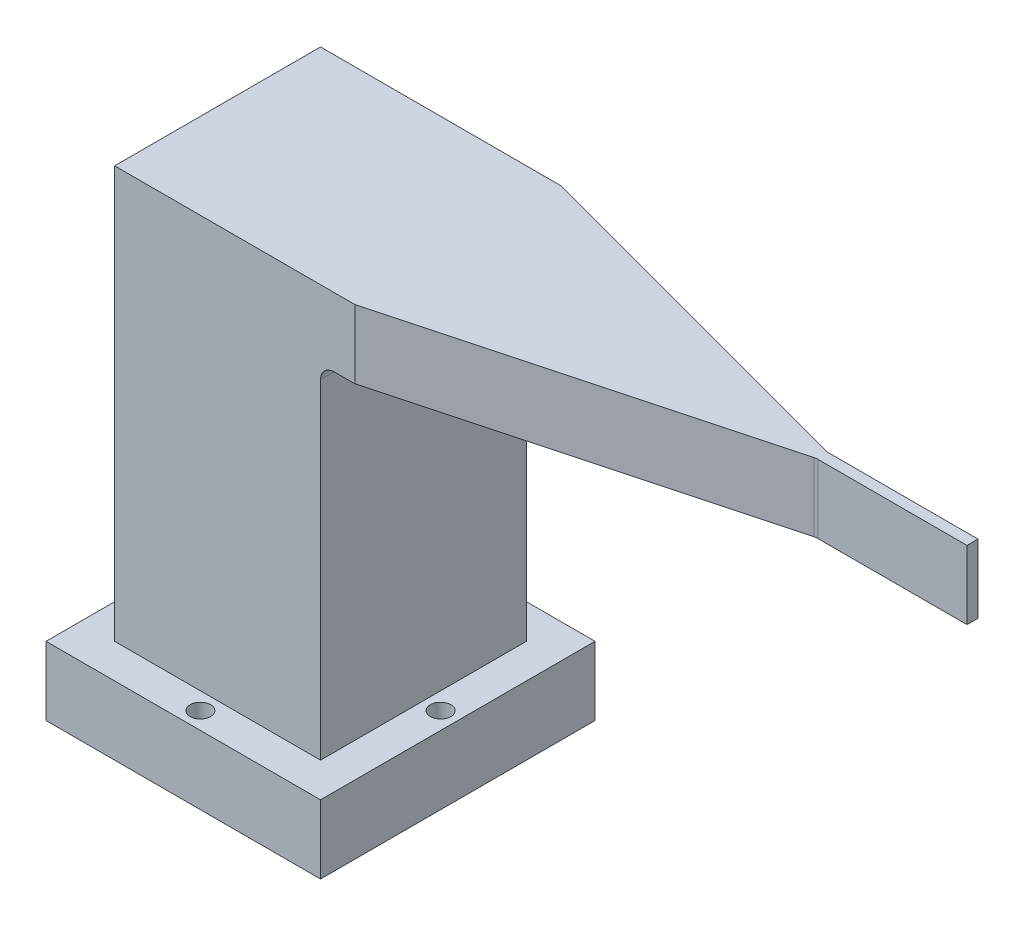
from build123d import *

# Parameters (mm, degrees)
ESQUISSE1_W             = 20
ESQUISSE1_H             = 20
BOSS_EXTRU_1_DEPTH      = 5
ESQUISSE2_W             = 15
ESQUISSE2_H             = 15
BOSS_EXTRU_2_DEPTH      = 35
ESQUISSE3_R             = 0.75
ENL_V_MAT_EXTRU_1_DEPTH = 5
ESQUISSE5_W             = 15
ESQUISSE5_H             = 5
BOSS_EXTRU_3_DEPTH      = 40
ENL_V_MAT_EXTRU_2_DEPTH = 5
CONG_1_R                = 1


with BuildPart() as part:
    # Esquisse1 → Boss.-Extru.1 (new body)
    with BuildSketch(Plane(origin=(0, 0, 0), x_dir=(1, 0, 0), z_dir=(0, 1, 0))):
        Rectangle(ESQUISSE1_W, ESQUISSE1_H)
    extrude(amount=BOSS_EXTRU_1_DEPTH)

    # Esquisse2 → Boss.-Extru.2 (add)
    with BuildSketch(Plane(origin=(0, 0, 0), x_dir=(-1, 0, 0), z_dir=(0, -1, 0))):
        Rectangle(ESQUISSE2_W, ESQUISSE2_H)
    extrude(amount=-BOSS_EXTRU_2_DEPTH)

    # Esquisse3 → Enlèv. mat.-Extru.1 (cut)
    with BuildSketch(Plane(origin=(0, 5, 0), x_dir=(1, 0, 0), z_dir=(0, 1, 0))):
        with Locations((-8.75, 0)):
            Circle(ESQUISSE3_R)
        with Locations((0, 8.75)):
            Circle(ESQUISSE3_R)
        with Locations((8.75, 0)):
            Circle(ESQUISSE3_R)
        with Locations((0, -8.75)):
            Circle(ESQUISSE3_R)
    extrude(amount=-ENL_V_MAT_EXTRU_1_DEPTH, mode=Mode.SUBTRACT)

    # Esquisse5 → Boss.-Extru.3 (add)
    with BuildSketch(Plane(origin=(7.5, 0, 0), x_dir=(0, 0, -1), z_dir=(1, 0, 0))):
        with Locations((0, 32.5)):
            Rectangle(ESQUISSE5_W, ESQUISSE5_H)
    extrude(amount=BOSS_EXTRU_3_DEPTH)

    # Esquisse6 → Enlèv. mat.-Extru.2 (cut)
    with BuildSketch(Plane(origin=(0, 35, 0), x_dir=(1, 0, 0), z_dir=(0, 1, 0))):
        Polygon((10, 7.5), (36.497560734, 0.4), (47.5, 0.4), (47.5, 7.5), align=None)
        Polygon((36.497560734, -0.4), (47.5, -0.4), (47.5, -7.5), (10, -7.5), align=None)
    extrude(amount=-ENL_V_MAT_EXTRU_2_DEPTH, mode=Mode.SUBTRACT)

    # Congé1
    cong_1_edges = [part.edges().sort_by_distance(p)[0] for p in [
        (7.5, 30, 0),
        (36.497560734, 32.5, -0.4),
        (36.497560734, 32.5, 0.4),
    ]]
    fillet(cong_1_edges, radius=CONG_1_R)


solid = part.part
